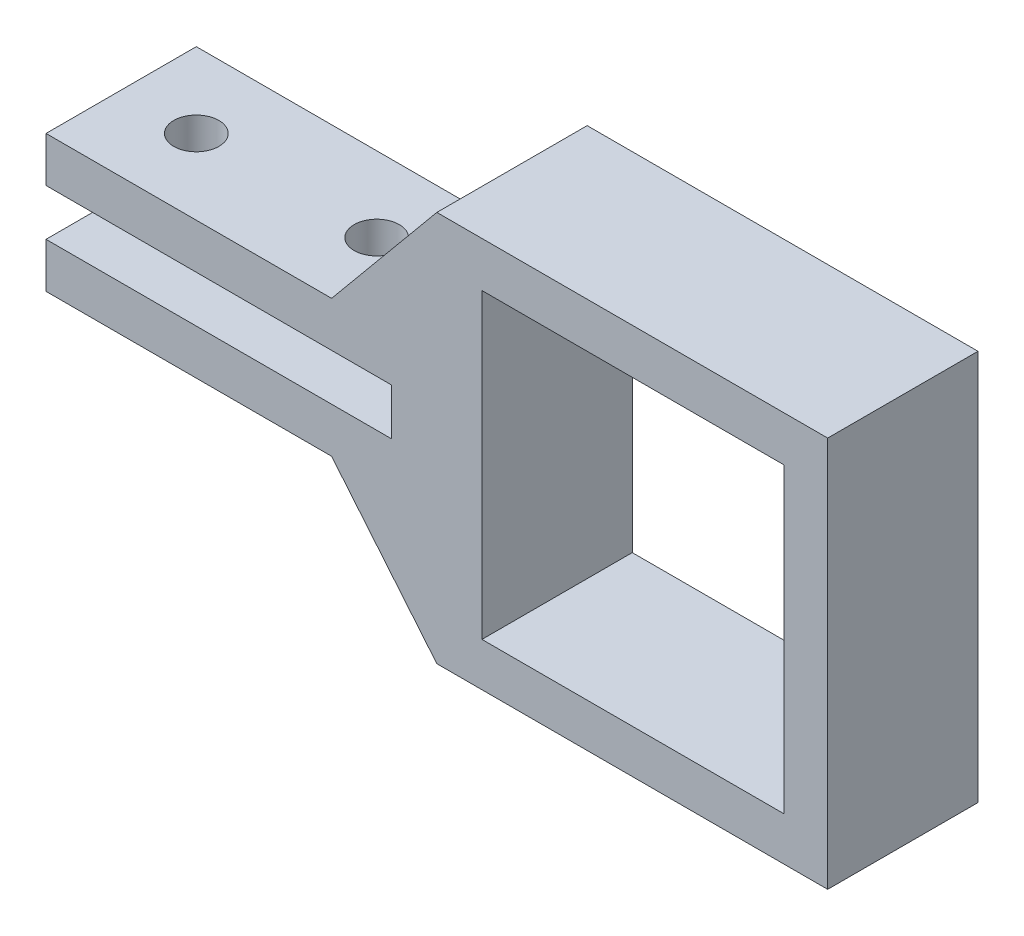
from build123d import *

# Parameters (mm, degrees)
EXTRUDE_1_DEPTH     = 10
SKETCH_5_W          = 20.1
SKETCH_5_H          = 20.1
CUT_EXTRUDE_1_DEPTH = 30
SKETCH_7_R          = 1.5
CUT_EXTRUDE_5_DEPTH = 9.1


with BuildPart() as part:
    # 草图1 → 凸台-拉伸1 (new body)
    with BuildSketch(Plane.XY):
        Polygon((-26, 4.55), (-26, 1.55), (-3, 1.55), (-3, -1.55), (-26, -1.55), (-26, -4.55), (-7, -4.55), (0, -13), (26, -13), (26, 13), (0, 13), (-7, 4.55), align=None)
    extrude(amount=EXTRUDE_1_DEPTH)

    # 草图5 → 切除-拉伸1 (cut)
    with BuildSketch(Plane.XY.offset(10)):
        with Locations((13.05, -0.05)):
            Rectangle(SKETCH_5_W, SKETCH_5_H)
    extrude(amount=-CUT_EXTRUDE_1_DEPTH, mode=Mode.SUBTRACT)

    # 草图7 → 切除-拉伸5 (cut)
    with BuildSketch(Plane(origin=(0, 4.55, 0), x_dir=(1, 0, 0), z_dir=(0, 1, 0))):
        with Locations((-21, -5)):
            Circle(SKETCH_7_R)
        with Locations((-9, -5)):
            Circle(SKETCH_7_R)
    extrude(amount=-CUT_EXTRUDE_5_DEPTH, mode=Mode.SUBTRACT)


solid = part.part
